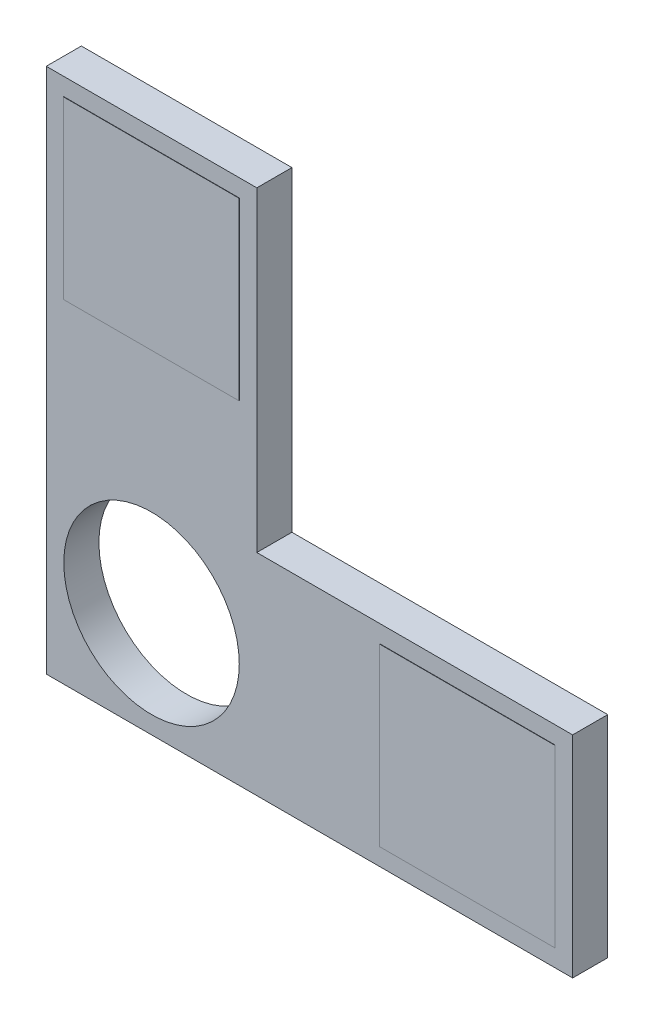
from build123d import *

# Parameters (mm, degrees)
SKETCH1_R           = 25
BOSS_EXTRUDE1_DEPTH = 10
SKETCH2_W           = 50
SKETCH2_H           = 50
BOSS_EXTRUDE2_DEPTH = 0.1


with BuildPart() as part:
    # Sketch1 → Boss-Extrude1 (new body)
    with BuildSketch(Plane.XY):
        Polygon((0, 0), (0, 150), (60, 150), (60, 60), (150, 60), (150, 0), align=None)
        with Locations((30, 30)):
            Circle(SKETCH1_R, mode=Mode.SUBTRACT)
    extrude(amount=BOSS_EXTRUDE1_DEPTH)

    # Sketch2 → Boss-Extrude2 (add)
    with BuildSketch(Plane.XY.offset(10)):
        with Locations((30, 120)):
            Rectangle(SKETCH2_W, SKETCH2_H)
        with Locations((120, 30)):
            Rectangle(SKETCH2_W, SKETCH2_H)
    extrude(amount=BOSS_EXTRUDE2_DEPTH)


solid = part.part
